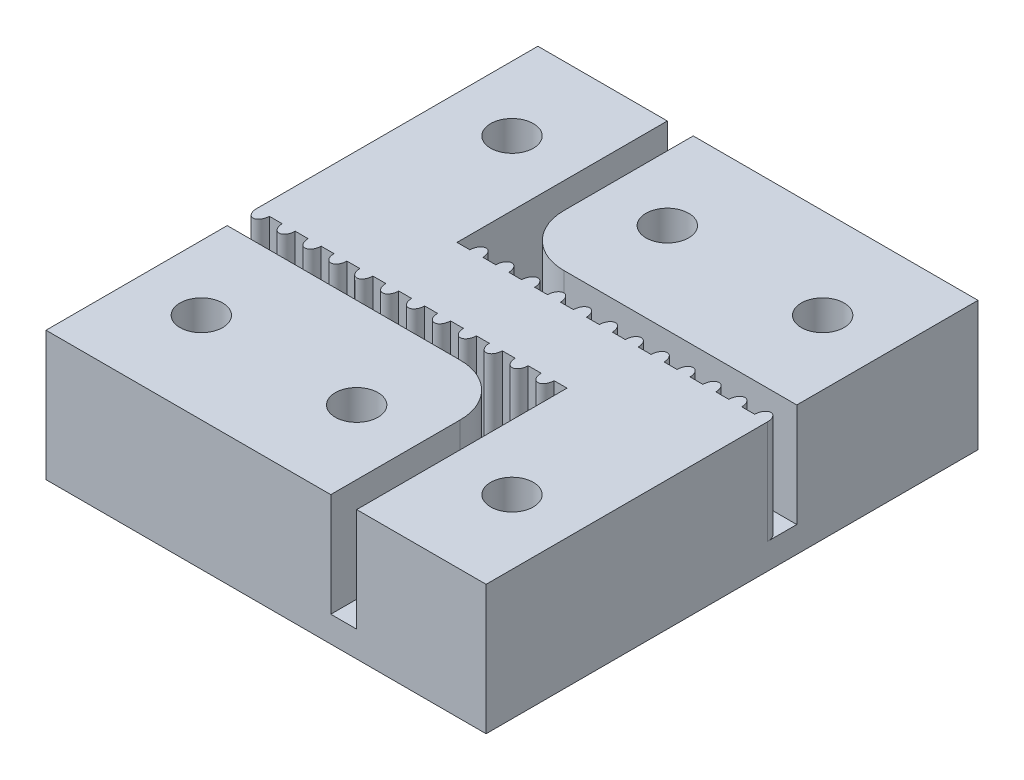
from build123d import *

# Parameters (mm, degrees)
SKETCH_1_W          = 34
SKETCH_1_H          = 38
EXTRUDE_1_DEPTH     = 10
SKETCH_2_R          = 1.65
CUT_EXTRUDE_1_DEPTH = 11
CUT_EXTRUDE_2_DEPTH = 8
FILLET_1_R          = 4
SKETCH_4_R          = 2.9
CUT_EXTRUDE_3_DEPTH = 3.2


with BuildPart() as part:
    # 草图1 → 凸台-拉伸1 (new body)
    with BuildSketch(Plane(origin=(0, 0, 0), x_dir=(1, 0, 0), z_dir=(0, 1, 0))):
        with Locations((17, 19)):
            Rectangle(SKETCH_1_W, SKETCH_1_H)
    extrude(amount=EXTRUDE_1_DEPTH)

    # 草图2 → 切除-拉伸1 (cut, through all)
    with BuildSketch(Plane(origin=(0, 10, 0), x_dir=(1, 0, 0), z_dir=(0, 1, 0))):
        with Locations((5, 7)):
            Circle(SKETCH_2_R)
        with Locations((17, 7)):
            Circle(SKETCH_2_R)
        with Locations((29, 7)):
            Circle(SKETCH_2_R)
        with Locations((17, 31)):
            Circle(SKETCH_2_R)
        with Locations((29, 31)):
            Circle(SKETCH_2_R)
        with Locations((5, 31)):
            Circle(SKETCH_2_R)
    extrude(amount=-CUT_EXTRUDE_1_DEPTH, mode=Mode.SUBTRACT)

    # 草图3 → 切除-拉伸2 (cut)
    with BuildSketch(Plane(origin=(0, 10, 0), x_dir=(1, 0, 0), z_dir=(0, 1, 0))):
        with BuildLine():
            Line((0, 14), (22, 14))
            Line((22, 14), (22, 0))
            Line((22, 0), (24, 0))
            Line((24, 0), (24, 16.25))
            Line((24, 16.25), (23, 16.25))
            add(Edge.make_bspline(
                [(22, 16.25), (22, 15.5), (22.5, 15.5), (23, 15.5), (23, 16.25)],
                knots=[4.71238898, 4.71238898, 4.71238898, 6.283185307, 6.283185307, 7.853981634, 7.853981634, 7.853981634], degree=2, weights=[1, 0.707106781, 1, 0.707106781, 1]))
            Line((22, 16.25), (21, 16.25))
            add(Edge.make_bspline(
                [(20, 16.25), (20, 15.5), (20.5, 15.5), (21, 15.5), (21, 16.25)],
                knots=[1.570796327, 1.570796327, 1.570796327, 3.141592654, 3.141592654, 4.71238898, 4.71238898, 4.71238898], degree=2, weights=[1, 0.707106781, 1, 0.707106781, 1]))
            Line((20, 16.25), (19, 16.25))
            add(Edge.make_bspline(
                [(18, 16.25), (18, 15.5), (18.5, 15.5), (19, 15.5), (19, 16.25)],
                knots=[4.71238898, 4.71238898, 4.71238898, 6.283185307, 6.283185307, 7.853981634, 7.853981634, 7.853981634], degree=2, weights=[1, 0.707106781, 1, 0.707106781, 1]))
            Line((18, 16.25), (17, 16.25))
            add(Edge.make_bspline(
                [(16, 16.25), (16, 15.5), (16.5, 15.5), (17, 15.5), (17, 16.25)],
                knots=[1.570796327, 1.570796327, 1.570796327, 3.141592654, 3.141592654, 4.71238898, 4.71238898, 4.71238898], degree=2, weights=[1, 0.707106781, 1, 0.707106781, 1]))
            Line((16, 16.25), (15, 16.25))
            add(Edge.make_bspline(
                [(14, 16.25), (14, 15.5), (14.5, 15.5), (15, 15.5), (15, 16.25)],
                knots=[4.71238898, 4.71238898, 4.71238898, 6.283185307, 6.283185307, 7.853981634, 7.853981634, 7.853981634], degree=2, weights=[1, 0.707106781, 1, 0.707106781, 1]))
            Line((14, 16.25), (13, 16.25))
            add(Edge.make_bspline(
                [(12, 16.25), (12, 15.5), (12.5, 15.5), (13, 15.5), (13, 16.25)],
                knots=[1.570796327, 1.570796327, 1.570796327, 3.141592654, 3.141592654, 4.71238898, 4.71238898, 4.71238898], degree=2, weights=[1, 0.707106781, 1, 0.707106781, 1]))
            Line((12, 16.25), (11, 16.25))
            add(Edge.make_bspline(
                [(10, 16.25), (10, 15.5), (10.5, 15.5), (11, 15.5), (11, 16.25)],
                knots=[4.71238898, 4.71238898, 4.71238898, 6.283185307, 6.283185307, 7.853981634, 7.853981634, 7.853981634], degree=2, weights=[1, 0.707106781, 1, 0.707106781, 1]))
            Line((10, 16.25), (9, 16.25))
            add(Edge.make_bspline(
                [(8, 16.25), (8, 15.5), (8.5, 15.5), (9, 15.5), (9, 16.25)],
                knots=[1.570796327, 1.570796327, 1.570796327, 3.141592654, 3.141592654, 4.71238898, 4.71238898, 4.71238898], degree=2, weights=[1, 0.707106781, 1, 0.707106781, 1]))
            Line((8, 16.25), (7, 16.25))
            add(Edge.make_bspline(
                [(6, 16.25), (6, 15.5), (6.5, 15.5), (7, 15.5), (7, 16.25)],
                knots=[4.71238898, 4.71238898, 4.71238898, 6.283185307, 6.283185307, 7.853981634, 7.853981634, 7.853981634], degree=2, weights=[1, 0.707106781, 1, 0.707106781, 1]))
            Line((6, 16.25), (5, 16.25))
            add(Edge.make_bspline(
                [(4, 16.25), (4, 15.5), (4.5, 15.5), (5, 15.5), (5, 16.25)],
                knots=[1.570796327, 1.570796327, 1.570796327, 3.141592654, 3.141592654, 4.71238898, 4.71238898, 4.71238898], degree=2, weights=[1, 0.707106781, 1, 0.707106781, 1]))
            Line((4, 16.25), (3, 16.25))
            add(Edge.make_bspline(
                [(2, 16.25), (2, 15.5), (2.5, 15.5), (3, 15.5), (3, 16.25)],
                knots=[4.71238898, 4.71238898, 4.71238898, 6.283185307, 6.283185307, 7.853981634, 7.853981634, 7.853981634], degree=2, weights=[1, 0.707106781, 1, 0.707106781, 1]))
            Line((2, 16.25), (1, 16.25))
            add(Edge.make_bspline(
                [(0, 16.25), (0, 15.5), (0.5, 15.5), (1, 15.5), (1, 16.25)],
                knots=[1.570796327, 1.570796327, 1.570796327, 3.141592654, 3.141592654, 4.71238898, 4.71238898, 4.71238898], degree=2, weights=[1, 0.707106781, 1, 0.707106781, 1]))
            Line((0, 16.25), (0, 14))
        make_face()
        with BuildLine():
            Line((10, 38), (10, 21.75))
            Line((10, 21.75), (11, 21.75))
            add(Edge.make_bspline(
                [(12, 21.75), (12, 22.5), (11.5, 22.5), (11, 22.5), (11, 21.75)],
                knots=[4.71238898, 4.71238898, 4.71238898, 6.283185307, 6.283185307, 7.853981634, 7.853981634, 7.853981634], degree=2, weights=[1, 0.707106781, 1, 0.707106781, 1]))
            Line((12, 21.75), (13, 21.75))
            add(Edge.make_bspline(
                [(14, 21.75), (14, 22.5), (13.5, 22.5), (13, 22.5), (13, 21.75)],
                knots=[4.71238898, 4.71238898, 4.71238898, 6.283185307, 6.283185307, 7.853981634, 7.853981634, 7.853981634], degree=2, weights=[1, 0.707106781, 1, 0.707106781, 1]))
            Line((14, 21.75), (15, 21.75))
            add(Edge.make_bspline(
                [(16, 21.75), (16, 22.5), (15.5, 22.5), (15, 22.5), (15, 21.75)],
                knots=[4.71238898, 4.71238898, 4.71238898, 6.283185307, 6.283185307, 7.853981634, 7.853981634, 7.853981634], degree=2, weights=[1, 0.707106781, 1, 0.707106781, 1]))
            Line((16, 21.75), (17, 21.75))
            add(Edge.make_bspline(
                [(18, 21.75), (18, 22.5), (17.5, 22.5), (17, 22.5), (17, 21.75)],
                knots=[1.570796327, 1.570796327, 1.570796327, 3.141592654, 3.141592654, 4.71238898, 4.71238898, 4.71238898], degree=2, weights=[1, 0.707106781, 1, 0.707106781, 1]))
            Line((18, 21.75), (19, 21.75))
            add(Edge.make_bspline(
                [(20, 21.75), (20, 22.5), (19.5, 22.5), (19, 22.5), (19, 21.75)],
                knots=[4.71238898, 4.71238898, 4.71238898, 6.283185307, 6.283185307, 7.853981634, 7.853981634, 7.853981634], degree=2, weights=[1, 0.707106781, 1, 0.707106781, 1]))
            Line((20, 21.75), (21, 21.75))
            add(Edge.make_bspline(
                [(22, 21.75), (22, 22.5), (21.5, 22.5), (21, 22.5), (21, 21.75)],
                knots=[1.570796327, 1.570796327, 1.570796327, 3.141592654, 3.141592654, 4.71238898, 4.71238898, 4.71238898], degree=2, weights=[1, 0.707106781, 1, 0.707106781, 1]))
            Line((22, 21.75), (23, 21.75))
            add(Edge.make_bspline(
                [(24, 21.75), (24, 22.5), (23.5, 22.5), (23, 22.5), (23, 21.75)],
                knots=[4.71238898, 4.71238898, 4.71238898, 6.283185307, 6.283185307, 7.853981634, 7.853981634, 7.853981634], degree=2, weights=[1, 0.707106781, 1, 0.707106781, 1]))
            Line((24, 21.75), (25, 21.75))
            add(Edge.make_bspline(
                [(26, 21.75), (26, 22.5), (25.5, 22.5), (25, 22.5), (25, 21.75)],
                knots=[1.570796327, 1.570796327, 1.570796327, 3.141592654, 3.141592654, 4.71238898, 4.71238898, 4.71238898], degree=2, weights=[1, 0.707106781, 1, 0.707106781, 1]))
            Line((26, 21.75), (27, 21.75))
            add(Edge.make_bspline(
                [(28, 21.75), (28, 22.5), (27.5, 22.5), (27, 22.5), (27, 21.75)],
                knots=[4.71238898, 4.71238898, 4.71238898, 6.283185307, 6.283185307, 7.853981634, 7.853981634, 7.853981634], degree=2, weights=[1, 0.707106781, 1, 0.707106781, 1]))
            Line((28, 21.75), (29, 21.75))
            add(Edge.make_bspline(
                [(30, 21.75), (30, 22.5), (29.5, 22.5), (29, 22.5), (29, 21.75)],
                knots=[1.570796327, 1.570796327, 1.570796327, 3.141592654, 3.141592654, 4.71238898, 4.71238898, 4.71238898], degree=2, weights=[1, 0.707106781, 1, 0.707106781, 1]))
            Line((30, 21.75), (31, 21.75))
            add(Edge.make_bspline(
                [(32, 21.75), (32, 22.5), (31.5, 22.5), (31, 22.5), (31, 21.75)],
                knots=[4.71238898, 4.71238898, 4.71238898, 6.283185307, 6.283185307, 7.853981634, 7.853981634, 7.853981634], degree=2, weights=[1, 0.707106781, 1, 0.707106781, 1]))
            Line((32, 21.75), (33, 21.75))
            add(Edge.make_bspline(
                [(34, 21.75), (34, 22.5), (33.5, 22.5), (33, 22.5), (33, 21.75)],
                knots=[1.570796327, 1.570796327, 1.570796327, 3.141592654, 3.141592654, 4.71238898, 4.71238898, 4.71238898], degree=2, weights=[1, 0.707106781, 1, 0.707106781, 1]))
            Line((34, 21.75), (34, 24))
            Line((34, 24), (12, 24))
            Line((12, 24), (12, 38))
            Line((12, 38), (10, 38))
        make_face()
    extrude(amount=-CUT_EXTRUDE_2_DEPTH, mode=Mode.SUBTRACT)

    # 圆角1
    fillet_1_edges = [part.edges().sort_by_distance(p)[0] for p in [
        (12, 6, -24),
        (22, 6, -14),
    ]]
    fillet(fillet_1_edges, radius=FILLET_1_R)

    # 草图4 → 切除-拉伸3 (cut)
    with BuildSketch(Plane.XZ):
        with Locations((5, -7)):
            Circle(SKETCH_4_R)
        with Locations((17, -7)):
            Circle(SKETCH_4_R)
        with Locations((29, -7)):
            Circle(SKETCH_4_R)
        with Locations((17, -31)):
            Circle(SKETCH_4_R)
        with Locations((29, -31)):
            Circle(SKETCH_4_R)
        with Locations((5, -31)):
            Circle(SKETCH_4_R)
    extrude(amount=-CUT_EXTRUDE_3_DEPTH, mode=Mode.SUBTRACT)


solid = part.part
